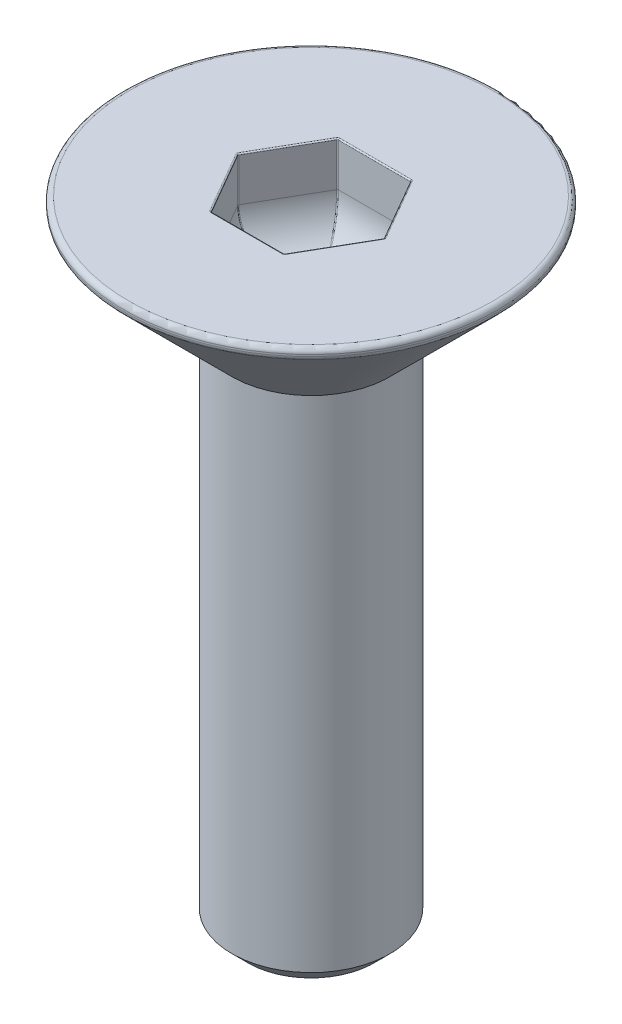
from build123d import *

# Parameters (mm, degrees)
SKETCH8_W          = 1.25
SKETCH8_H          = 10
CHAMFER1_SIZE      = 0.25
CHAMFER2_SIZE2     = 0.2
CHAMFER2_SIZE      = 0.141421
FILLET1_R          = 0.08
CUT_EXTRUDE1_DEPTH = 1.5
FILLET2_R          = 0.8
FILLET5_R          = 0.02


with BuildPart() as part:
    # Sketch8 → Revolve1 (revolve)
    with BuildSketch(Plane.XY):
        with Locations((0.625, -5)):
            Rectangle(SKETCH8_W, SKETCH8_H)
    revolve(axis=Axis((0, 0, 0), (0, -1, 0)))

    # Chamfer1
    chamfer1_edges = [part.edges().sort_by_distance(p)[0] for p in [
        (-1.25, -10, 0),
    ]]
    chamfer(chamfer1_edges, length=CHAMFER1_SIZE)

    # Sketch13 → Revolve2 (revolve)
    with BuildSketch(Plane.XY):
        Polygon((0, 0), (3.1, 0), (0, -3.1), align=None)
    revolve(axis=Axis((0, 0, 0), (0, -1, 0)))

    # Chamfer2
    chamfer2_edges = [part.edges().sort_by_distance(p)[0] for p in [
        (-3.1, 0, 0),
    ]]
    chamfer(chamfer2_edges, length=CHAMFER2_SIZE, length2=CHAMFER2_SIZE2)

    # Fillet1
    fillet1_edges = [part.edges().sort_by_distance(p)[0] for p in [
        (-2.958578, 0, 0),
        (-2.958578, -0.141421, 0),
    ]]
    fillet(fillet1_edges, radius=FILLET1_R)

    # Sketch14 → Cut-Extrude1 (cut)
    with BuildSketch(Plane(origin=(0, 0, 0), x_dir=(1, 0, 0), z_dir=(0, 1, 0))):
        Polygon((1.154701, 0), (0.57735, 1), (-0.57735, 1), (-1.154701, 0), (-0.57735, -1), (0.57735, -1), align=None)
    extrude(amount=-CUT_EXTRUDE1_DEPTH, mode=Mode.SUBTRACT)

    # Fillet2
    fillet2_edges = [part.edges().sort_by_distance(p)[0] for p in [
        (0.866025, -1.5, 0.5),
        (0, -1.5, 1),
        (-0.866025, -1.5, 0.5),
        (-0.866025, -1.5, -0.5),
        (0, -1.5, -1),
        (0.866025, -1.5, -0.5),
    ]]
    fillet(fillet2_edges, radius=FILLET2_R)

    # Fillet5
    fillet5_edges = [part.edges().sort_by_distance(p)[0] for p in [
        (0.866025, 0, 0.5),
        (0.866025, 0, -0.5),
        (0, 0, -1),
        (-0.866025, 0, -0.5),
        (-0.866025, 0, 0.5),
        (0, 0, 1),
        (0.57735, -0.35, 1),
        (-0.57735, -0.35, 1),
        (-1.154701, -0.35, 0),
        (-0.57735, -0.35, -1),
        (0.57735, -0.35, -1),
        (1.154701, -0.35, 0),
        (-0.430209, -1.285507, -0.745143),
        (0.430209, -1.285507, -0.745143),
        (-0.860417, -1.285507, 0),
        (0.860417, -1.285507, 0),
        (-0.430209, -1.285507, 0.745143),
        (0.430209, -1.285507, 0.745143),
    ]]
    fillet(fillet5_edges, radius=FILLET5_R)


solid = part.part
